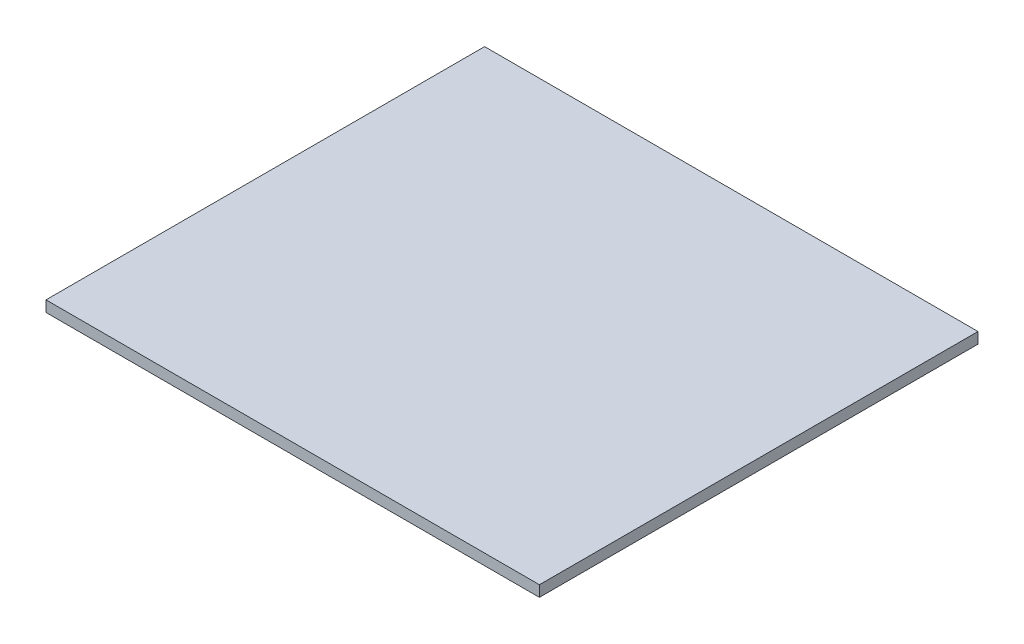
from build123d import *

# Parameters (mm, degrees)
SKETCH1_W           = 228.6
SKETCH1_H           = 203.2
BOSS_EXTRUDE1_DEPTH = 5.08


with BuildPart() as part:
    # Sketch1 → Boss-Extrude1 (new body)
    with BuildSketch(Plane(origin=(0, 0, 0), x_dir=(1, 0, 0), z_dir=(0, 1, 0))):
        with Locations((53.665458187, -63.461751961)):
            Rectangle(SKETCH1_W, SKETCH1_H)
    extrude(amount=BOSS_EXTRUDE1_DEPTH)


solid = part.part
